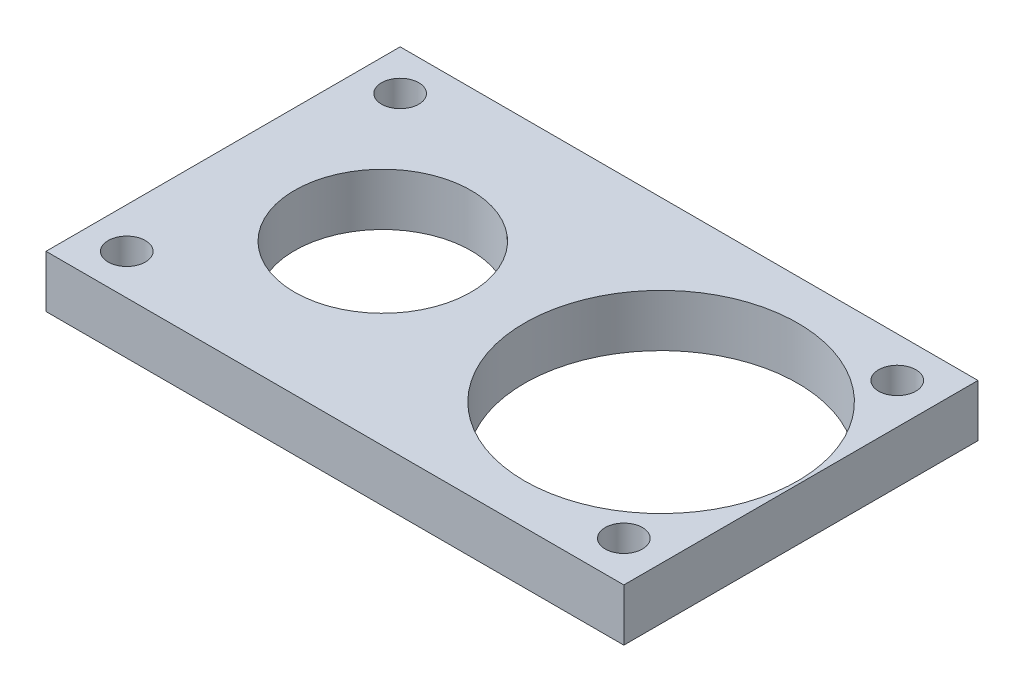
from build123d import *

# Parameters (mm, degrees)
SKETCH11_W          = 46.5
SKETCH11_H          = 28.5
SKETCH11_R          = 1.5
BOSS_EXTRUDE3_DEPTH = 4.2
SKETCH12_R          = 11
CUT_EXTRUDE6_DEPTH  = 5.2
SKETCH13_R          = 7.1
CUT_EXTRUDE7_DEPTH  = 5.2


with BuildPart() as part:
    # Sketch11 → Boss-Extrude3 (new body)
    with BuildSketch(Plane(origin=(0, 0, 0), x_dir=(1, 0, 0), z_dir=(0, 1, 0))):
        with Locations((-5.6, 0)):
            Rectangle(SKETCH11_W, SKETCH11_H)
        with Locations((-25.6, 11)):
            Circle(SKETCH11_R, mode=Mode.SUBTRACT)
        with Locations((14.4, 11)):
            Circle(SKETCH11_R, mode=Mode.SUBTRACT)
        with Locations((14.4, -11)):
            Circle(SKETCH11_R, mode=Mode.SUBTRACT)
        with Locations((-25.6, -11)):
            Circle(SKETCH11_R, mode=Mode.SUBTRACT)
    extrude(amount=-BOSS_EXTRUDE3_DEPTH)

    # Sketch12 → Cut-Extrude6 (cut, through all)
    with BuildSketch(Plane(origin=(0, 0, 0), x_dir=(1, 0, 0), z_dir=(0, 1, 0))):
        with Locations((6.4, 0)):
            Circle(SKETCH12_R)
    extrude(amount=-CUT_EXTRUDE6_DEPTH, mode=Mode.SUBTRACT)

    # Sketch13 → Cut-Extrude7 (cut, through all)
    with BuildSketch(Plane(origin=(0, 0, 0), x_dir=(1, 0, 0), z_dir=(0, 1, 0))):
        with Locations((-16, 0)):
            Circle(SKETCH13_R)
    extrude(amount=-CUT_EXTRUDE7_DEPTH, mode=Mode.SUBTRACT)


solid = part.part
